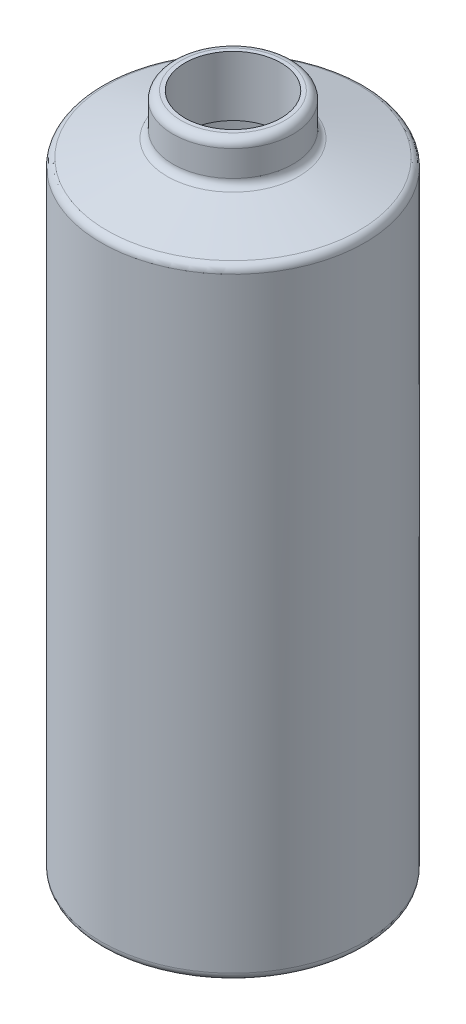
from build123d import *

# Parameters (mm, degrees)
SKETCH1_R           = 41.91
BOSS_EXTRUDE1_DEPTH = 196.85
SKETCH6_R           = 19.05
BOSS_EXTRUDE4_DEPTH = 12.7
SHELL7_T            = -3.81
CUT_EXTRUDE2_REACH  = 225.888
SKETCH13_R          = 15.24
FILLET12_R          = 2.54


with BuildPart() as part:
    # Sketch1 → Boss-Extrude1 (new body)
    with BuildSketch(Plane(origin=(0, 0, 0), x_dir=(1, 0, 0), z_dir=(0, 1, 0))):
        with Locations(Location((0, 0, 0), (0, 0, 270))):
            Circle(SKETCH1_R)
    extrude(amount=BOSS_EXTRUDE1_DEPTH)

    # Shell7
    shell7_openings = [part.faces().sort_by_distance(p)[0] for p in [
        (0, 196.85, 0),
    ]]
    offset(amount=SHELL7_T, openings=shell7_openings, kind=Kind.INTERSECTION)



with BuildPart() as body_2:
    # Sketch6 → Boss-Extrude4 (new body)
    with BuildSketch(Plane(origin=(0, 203.2, 0), x_dir=(1, 0, 0), z_dir=(0, 1, 0))):
        with Locations(Location((0, 0, 0), (0, 0, 270))):
            Circle(SKETCH6_R)
    extrude(amount=BOSS_EXTRUDE4_DEPTH)


with BuildPart() as part_1:
    add(part.part)

    add(body_2.part)  # loft3 joins it to this body
    # loft up to a face of the part (loft3)
    loft([Face(Wire([part_1.edges().sort_by_distance((30.551075175, 196.85, -28.689369209))[0]])), Face(Wire([part_1.edges().sort_by_distance((-13.886852352, 203.2, -13.040622368))[0]]))])

    # Sketch13 → Cut-Extrude2 (cut, up to next)
    with BuildSketch(Plane(origin=(0, 215.9, 0), x_dir=(1, 0, 0), z_dir=(0, 1, 0)), mode=Mode.PRIVATE) as cut_extrude2_sk1:
        with Locations(Location((0, 0, 0), (0, 0, 270))):
            Circle(SKETCH13_R)
    cut_extrude2_tool1 = extrude(cut_extrude2_sk1.sketch, amount=-CUT_EXTRUDE2_REACH, mode=Mode.PRIVATE) & part_1.part
    add(cut_extrude2_tool1.solids().sort_by_distance((0, 215.9, 0))[0], mode=Mode.SUBTRACT)

    # Fillet12
    fillet12_edges = [part_1.edges().sort_by_distance(p)[0] for p in [
        (0, 215.9, -19.05),
        (0, 0, -41.91),
        (0, 196.85, -41.91),
        (0, 203.2, -19.05),
    ]]
    fillet(fillet12_edges, radius=FILLET12_R)


solid = part_1.part
